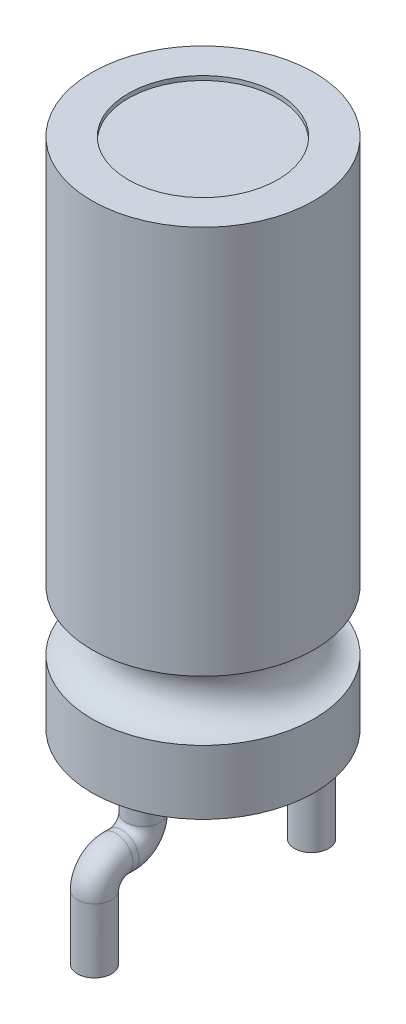
from build123d import *

# Parameters (mm, degrees)
ESQUISSE2_R             = 1.75
ENL_V_MAT_EXTRU_1_DEPTH = 0.1
ESQUISSE3_R             = 0.4
ESQUISSE6_R             = 0.4


with BuildPart() as part:
    # Esquisse1 → Révolution1 (revolve)
    with BuildSketch(Plane.XY, mode=Mode.PRIVATE) as r_volution1_sk:
        with BuildLine():
            Line((0, 39.516423663), (2.6, 39.516423663))
            Line((2.6, 39.516423663), (2.6, 30.416423663))
            ThreePointArc((2.6, 30.416423663), (1.9, 29.716423663), (2.6, 29.016423663))
            Line((2.6, 29.016423663), (2.6, 27.516423663))
            Line((2.6, 27.516423663), (0, 27.516423663))
            Line((0, 27.516423663), (0, 39.516423663))
        make_face()
    revolve(r_volution1_sk.sketch.rotate(Axis((0, 48.401709402, 0), (0, -1, 0)), 90), axis=Axis((0, 48.401709402, 0), (0, -1, 0)))  # turned: the seam where the file's is

    # Esquisse2 → Enlèv. mat.-Extru.1 (cut)
    with BuildSketch(Plane(origin=(0, 39.516423663, 0), x_dir=(-1, 0, 0), z_dir=(0, 1, 0))):
        with Locations(Location((0, 0, 0), (0, 0, 90))):  # turned: the seam where the file's is
            Circle(ESQUISSE2_R)
    extrude(amount=-ENL_V_MAT_EXTRU_1_DEPTH, mode=Mode.SUBTRACT)

    # Balayage2: sweep along a path in Esquisse4
    with BuildLine(Plane(origin=(0, 0, 0), x_dir=(0, 0, -1), z_dir=(1, 0, 0))) as balayage2_path:
        Line((-1.4, 27.516423663), (-1.4, 26.516423663))
        ThreePointArc((-1.4, 26.516423663), (-1.546446609, 26.162870273), (-1.9, 26.016423663))
        Line((-1.9, 26.016423663), (-2.04, 26.016423663))
        ThreePointArc((-2.04, 26.016423663), (-2.393553391, 25.869977054), (-2.54, 25.516423663))
        Line((-2.54, 25.516423663), (-2.54, 24.016423663))
    # Esquisse3 → Balayage2 (sweep)
    with BuildSketch(Plane.XZ.offset(-27.516423663)):
        with Locations((0, 1.4)):
            Circle(ESQUISSE3_R)
    sweep(path=balayage2_path.line)

    # Balayage3: sweep along a path in Esquisse7
    with BuildLine(Plane(origin=(0, 0, 0), x_dir=(0, 0, -1), z_dir=(1, 0, 0))) as balayage3_path:
        Line((1.4, 27.516423663), (1.4, 26.516423663))
        ThreePointArc((1.4, 26.516423663), (1.546446609, 26.162870273), (1.9, 26.016423663))
        Line((1.9, 26.016423663), (2.04, 26.016423663))
        ThreePointArc((2.04, 26.016423663), (2.393553391, 25.869977054), (2.54, 25.516423663))
        Line((2.54, 25.516423663), (2.54, 24.016423663))
    # Esquisse6 → Balayage3 (sweep)
    with BuildSketch(Plane.XZ.offset(-27.516423663)):
        with Locations((0, -1.4)):
            Circle(ESQUISSE6_R)
    sweep(path=balayage3_path.line)


solid = part.part
